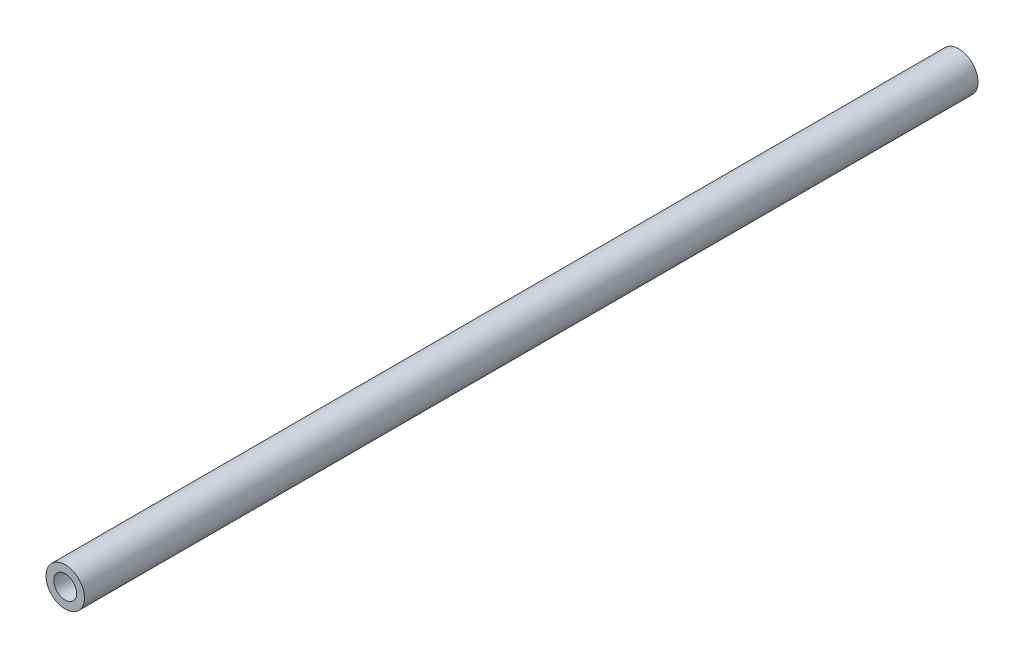
from build123d import *

# Parameters (mm, degrees)
SKETCH1_R           = 7.9
SKETCH1_R_2         = 4.7
BOSS_EXTRUDE1_DEPTH = 366.7


with BuildPart() as part:
    # Sketch1 → Boss-Extrude1 (new body)
    with BuildSketch(Plane.XY):
        Circle(SKETCH1_R)
        Circle(SKETCH1_R_2, mode=Mode.SUBTRACT)
    extrude(amount=BOSS_EXTRUDE1_DEPTH)


solid = part.part
